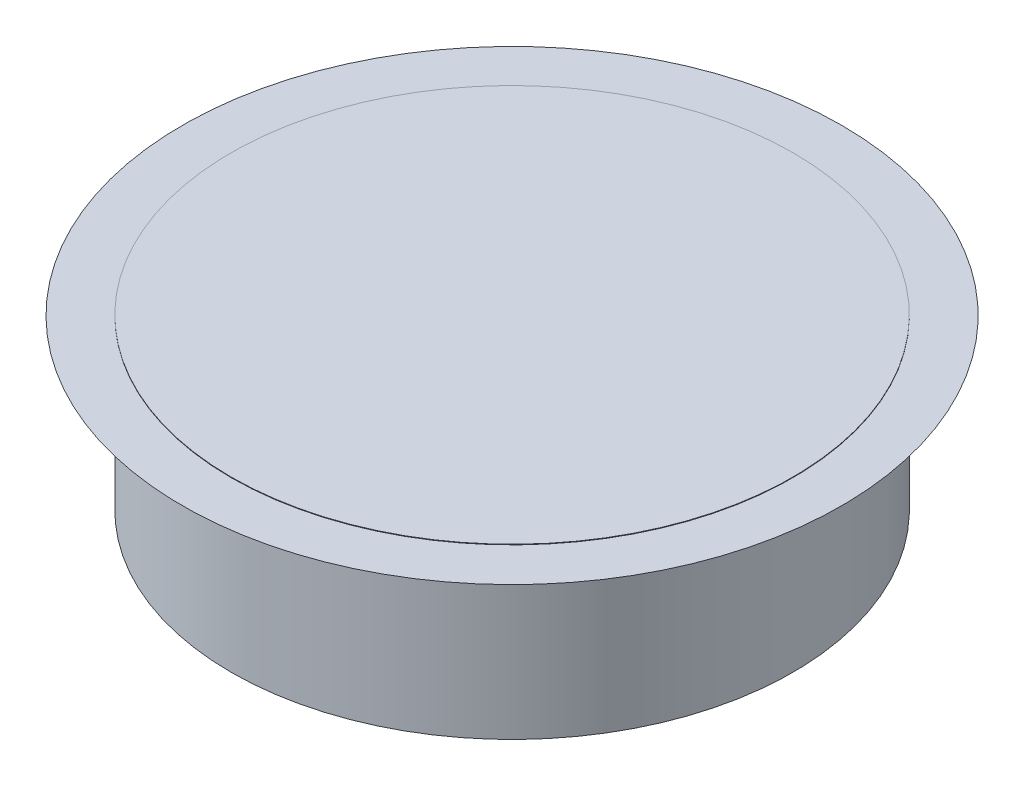
from build123d import *

# Parameters (mm, degrees)
SKETCH2_R           = 12.7
BOSS_EXTRUDE1_DEPTH = 0.0254


with BuildPart() as part:
    # Sketch1 → Revolve1 (revolve)
    with BuildSketch(Plane.XY):
        Polygon((0, 0), (-12.7, 0), (-12.7, 6.35), (-14.899704526, 7.62), (0, 7.62), align=None)
    revolve(axis=Axis((0, 0, 0), (0, 1, 0)))

    # Sketch2 → Boss-Extrude1 (add)
    with BuildSketch(Plane(origin=(0, 7.62, 0), x_dir=(1, 0, 0), z_dir=(0, 1, 0))):
        Circle(SKETCH2_R)
    extrude(amount=BOSS_EXTRUDE1_DEPTH)


solid = part.part
